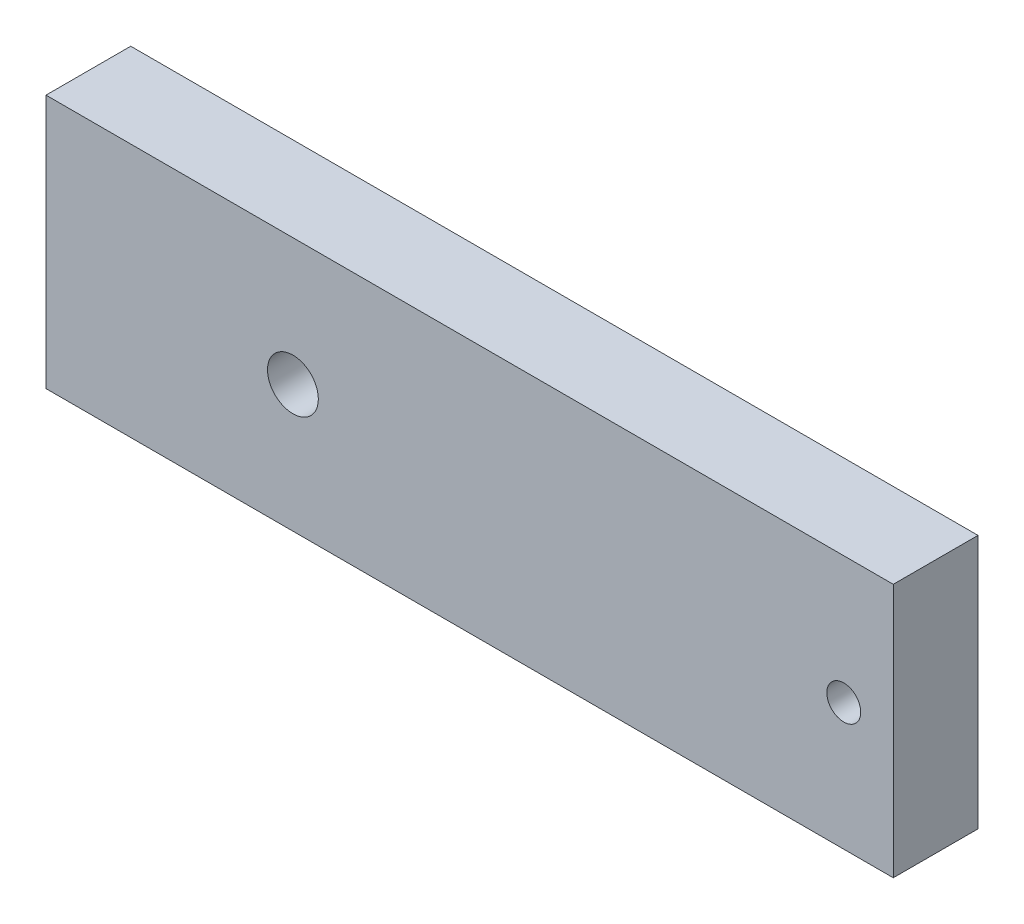
from build123d import *

# Parameters (mm, degrees)
SKETCH2_W           = 50
SKETCH2_H           = 15
BOSS_EXTRUDE1_DEPTH = 5
SKETCH3_R           = 1.5
CUT_EXTRUDE1_DEPTH  = 6
SKETCH4_R           = 1
CUT_EXTRUDE2_DEPTH  = 6


with BuildPart() as part:
    # Sketch2 → Boss-Extrude1 (new body)
    with BuildSketch(Plane.XY):
        Rectangle(SKETCH2_W, SKETCH2_H)
    extrude(amount=BOSS_EXTRUDE1_DEPTH)

    # Sketch3 → Cut-Extrude1 (cut, through all)
    with BuildSketch(Plane.XY.offset(5)):
        with Locations((-10.429188339, 0)):
            Circle(SKETCH3_R)
    extrude(amount=-CUT_EXTRUDE1_DEPTH, mode=Mode.SUBTRACT)

    # Sketch4 → Cut-Extrude2 (cut, through all)
    with BuildSketch(Plane.XY.offset(5)):
        with Locations((22.078934641, 0)):
            Circle(SKETCH4_R)
    extrude(amount=-CUT_EXTRUDE2_DEPTH, mode=Mode.SUBTRACT)


solid = part.part
